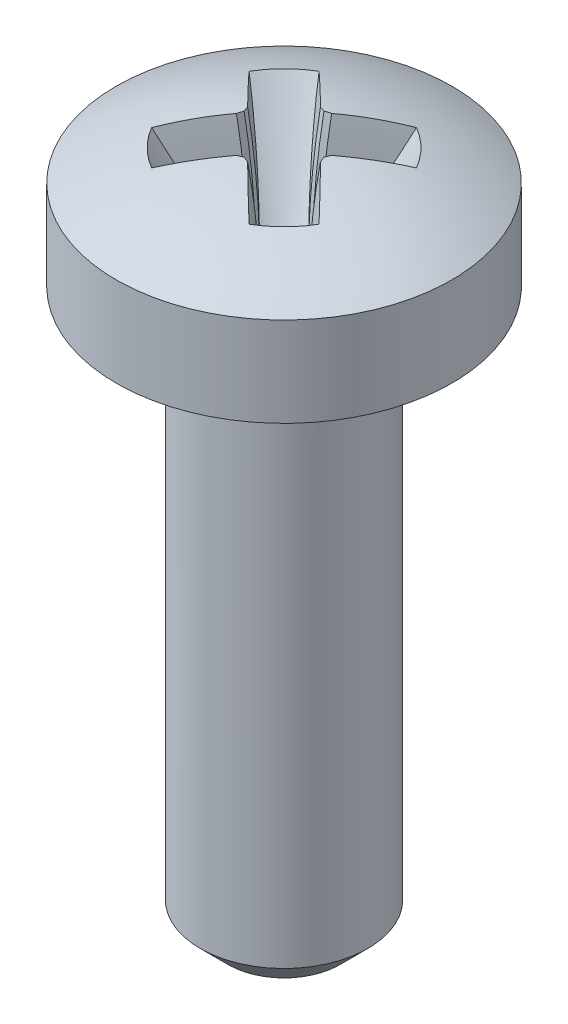
from build123d import *

# Parameters (mm, degrees)
R_P_TITION_CIRCULAIRE1_COUNT = 4


with BuildPart() as part:
    # Esquisse1 → Révolution1 (revolve)
    with BuildSketch(Plane.XY):
        with BuildLine():
            Line((0, 0), (-1, 0))
            Line((-1, 0), (-1.5, 0.5))
            Line((-1.5, 0.5), (-1.5, 10))
            Line((-1.5, 10), (-3, 10))
            Line((-3, 10), (-3, 11.6))
            ThreePointArc((-3, 11.6), (-1.55241747, 12.196565511), (0, 12.4))
            Line((0, 12.4), (0, 0))
        make_face()
    revolve(axis=Axis((0, 12.4, 0), (0, -1, 0)))


with BuildPart() as body_2:
    # Esquisse4 → Révolution2 (revolve)
    with BuildSketch(Plane.XY):
        Polygon((0, 20.1), (-3, 20.1), (-3, 14.343524479), (-0.55, 10.1), (0, 10.1), align=None)
    revolve(axis=Axis((0, 10.1, 0), (0, 1, 0)))

    # Esquisse5 → Enlèvement de matière-Révolution2 (revolve, cut)
    with BuildSketch(Plane.XZ.offset(-10.1)):
        Polygon((-12.5, 12.063602977), (-0.536397023, 0.1), (-0.5, 0), (-0.536397023, -0.1), (-12.5, -12.063602977), align=None)
    enl_vement_de_mati_re_r_volution2 = revolve(axis=Axis((-12.5, 10.1, -12.063602977), (0, 0, 1)), mode=Mode.SUBTRACT)

    # Répétition circulaire1: Enlèvement de matière-Révolution2 ×4 about axis
    r_p_tition_circulaire1_axis = Axis((0, 10.1, 0), (0, 1, 0))
    for i in range(1, R_P_TITION_CIRCULAIRE1_COUNT):
        add(enl_vement_de_mati_re_r_volution2.rotate(r_p_tition_circulaire1_axis, i * 360 / R_P_TITION_CIRCULAIRE1_COUNT), mode=Mode.SUBTRACT)


with BuildPart() as part_1:
    add(part.part)

    # Combiner1: cut body 2
    add(body_2.part, mode=Mode.SUBTRACT)


solid = part_1.part
